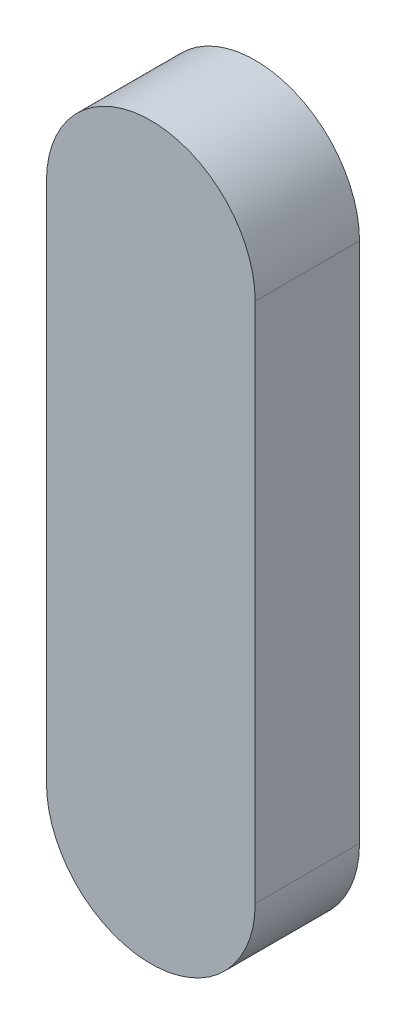
from build123d import *

# Parameters (mm, degrees)
EXTRUDE_1_DEPTH = 5


with BuildPart() as part:
    # 草图1 → 凸台-拉伸1 (new body)
    with BuildSketch(Plane.XY):
        with BuildLine():
            Line((5, 0), (5, -25))
            ThreePointArc((5, -25), (0, -30), (-5, -25))
            Line((-5, -25), (-5, 0))
            ThreePointArc((-5, 0), (0, 5), (5, 0))
        make_face()
    extrude(amount=EXTRUDE_1_DEPTH)


solid = part.part
